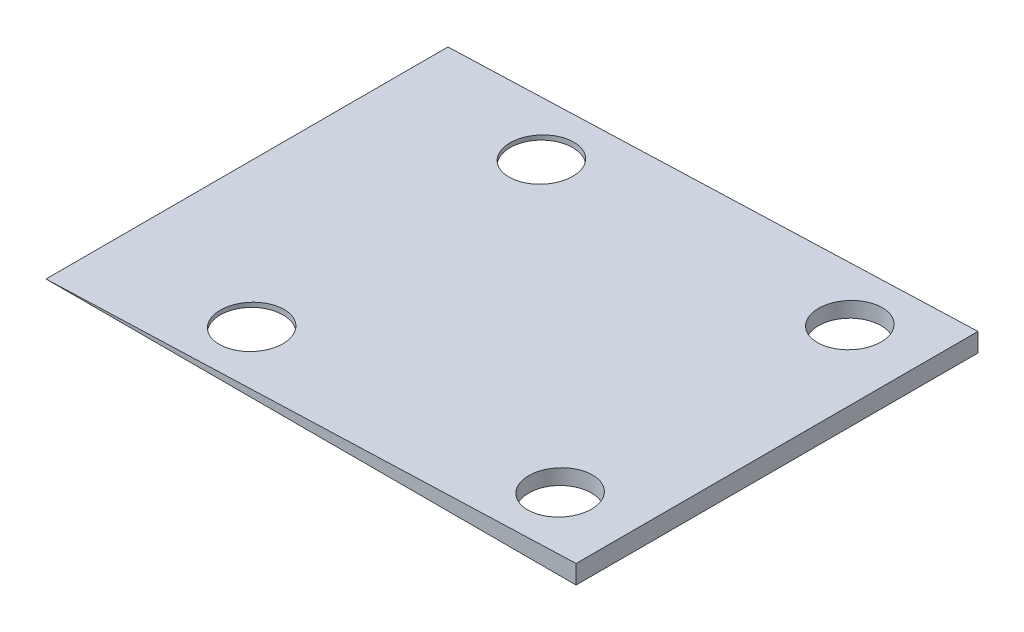
from build123d import *

# Parameters (mm, degrees)
BOSS_EXTRUDE1_DEPTH = 43
CUT_EXTRUDE1_REACH  = 4
SKETCH2_R           = 3.35


with BuildPart() as part:
    # Sketch1 → Boss-Extrude1 (new body)
    with BuildSketch(Plane.XY):
        Polygon((0, 0), (56.71, 0), (56.71, 2), align=None)
    extrude(amount=BOSS_EXTRUDE1_DEPTH)

    # Cut-Extrude1: up to this face of the body (flat: up to its plane)
    cut_extrude1_end = Plane(part.part.faces().sort_by_distance((28.355, 1, 21.5))[0])
    # Sketch2 → Cut-Extrude1 (cut, up to the picked face)
    with BuildSketch(Plane.XZ, mode=Mode.PRIVATE) as cut_extrude1_sk1:
        with Locations((49, 6)):
            Circle(SKETCH2_R)
    cut_extrude1_tool1 = split(extrude(cut_extrude1_sk1.sketch, amount=-CUT_EXTRUDE1_REACH, mode=Mode.PRIVATE), bisect_by=cut_extrude1_end, keep=Keep.BOTH, mode=Mode.PRIVATE)
    add(cut_extrude1_tool1.solids().sort_by_distance((49, 0, 6))[0], mode=Mode.SUBTRACT)
    # Sketch2 → Cut-Extrude1 (cut, up to the picked face)
    with BuildSketch(Plane.XZ, mode=Mode.PRIVATE) as cut_extrude1_sk2:
        with Locations((49, 37)):
            Circle(SKETCH2_R)
    cut_extrude1_tool2 = split(extrude(cut_extrude1_sk2.sketch, amount=-CUT_EXTRUDE1_REACH, mode=Mode.PRIVATE), bisect_by=cut_extrude1_end, keep=Keep.BOTH, mode=Mode.PRIVATE)
    add(cut_extrude1_tool2.solids().sort_by_distance((49, 0, 37))[0], mode=Mode.SUBTRACT)
    # Sketch2 → Cut-Extrude1 (cut, up to the picked face)
    with BuildSketch(Plane.XZ, mode=Mode.PRIVATE) as cut_extrude1_sk3:
        with Locations((16, 37)):
            Circle(SKETCH2_R)
    cut_extrude1_tool3 = split(extrude(cut_extrude1_sk3.sketch, amount=-CUT_EXTRUDE1_REACH, mode=Mode.PRIVATE), bisect_by=cut_extrude1_end, keep=Keep.BOTH, mode=Mode.PRIVATE)
    add(cut_extrude1_tool3.solids().sort_by_distance((16, 0, 37))[0], mode=Mode.SUBTRACT)
    # Sketch2 → Cut-Extrude1 (cut, up to the picked face)
    with BuildSketch(Plane.XZ, mode=Mode.PRIVATE) as cut_extrude1_sk4:
        with Locations((16, 6)):
            Circle(SKETCH2_R)
    cut_extrude1_tool4 = split(extrude(cut_extrude1_sk4.sketch, amount=-CUT_EXTRUDE1_REACH, mode=Mode.PRIVATE), bisect_by=cut_extrude1_end, keep=Keep.BOTH, mode=Mode.PRIVATE)
    add(cut_extrude1_tool4.solids().sort_by_distance((16, 0, 6))[0], mode=Mode.SUBTRACT)


solid = part.part
